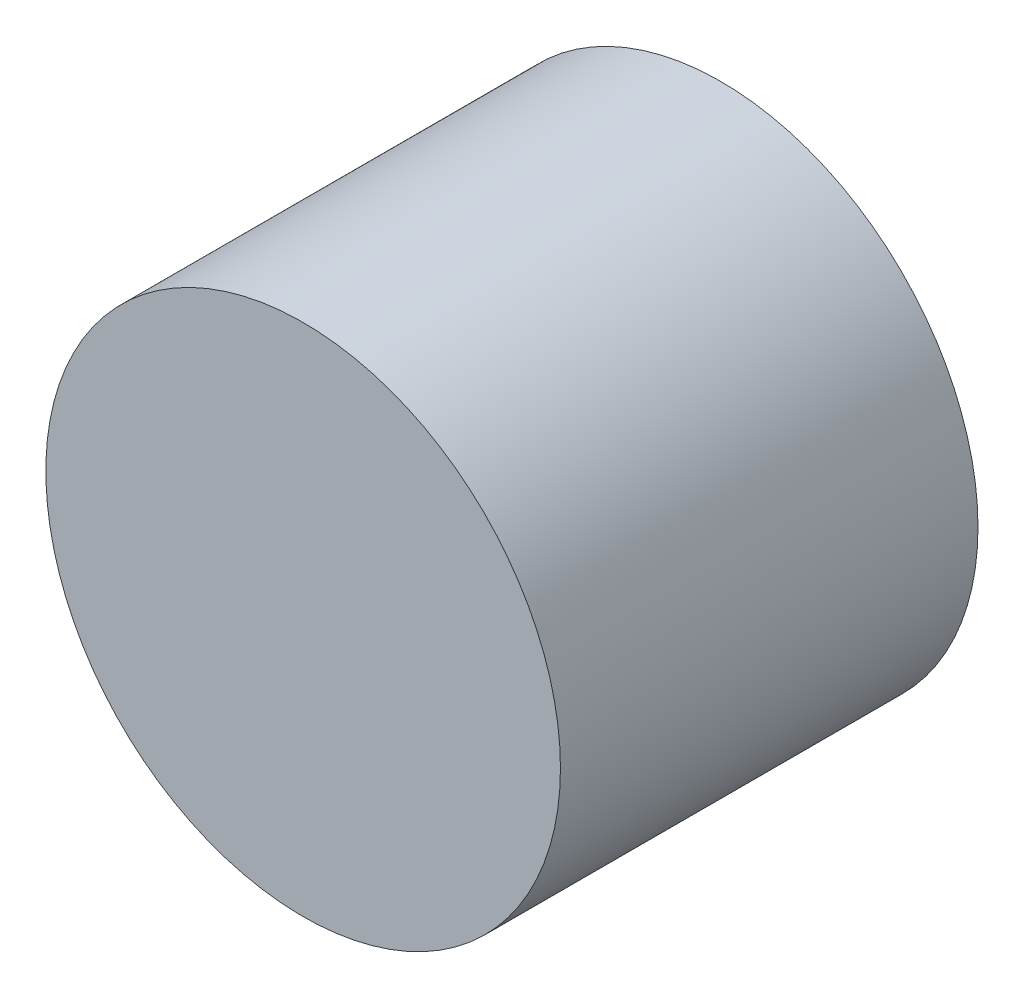
from build123d import *

# Parameters (mm, degrees)
SKETCH_1_R      = 1.232510044
EXTRUDE_1_DEPTH = 2


with BuildPart() as part:
    # 草图1 → 凸台-拉伸1 (new body)
    with BuildSketch(Plane.XY):
        with Locations((-17.516225754, 20.598490046)):
            Circle(SKETCH_1_R)
    extrude(amount=EXTRUDE_1_DEPTH)


solid = part.part
